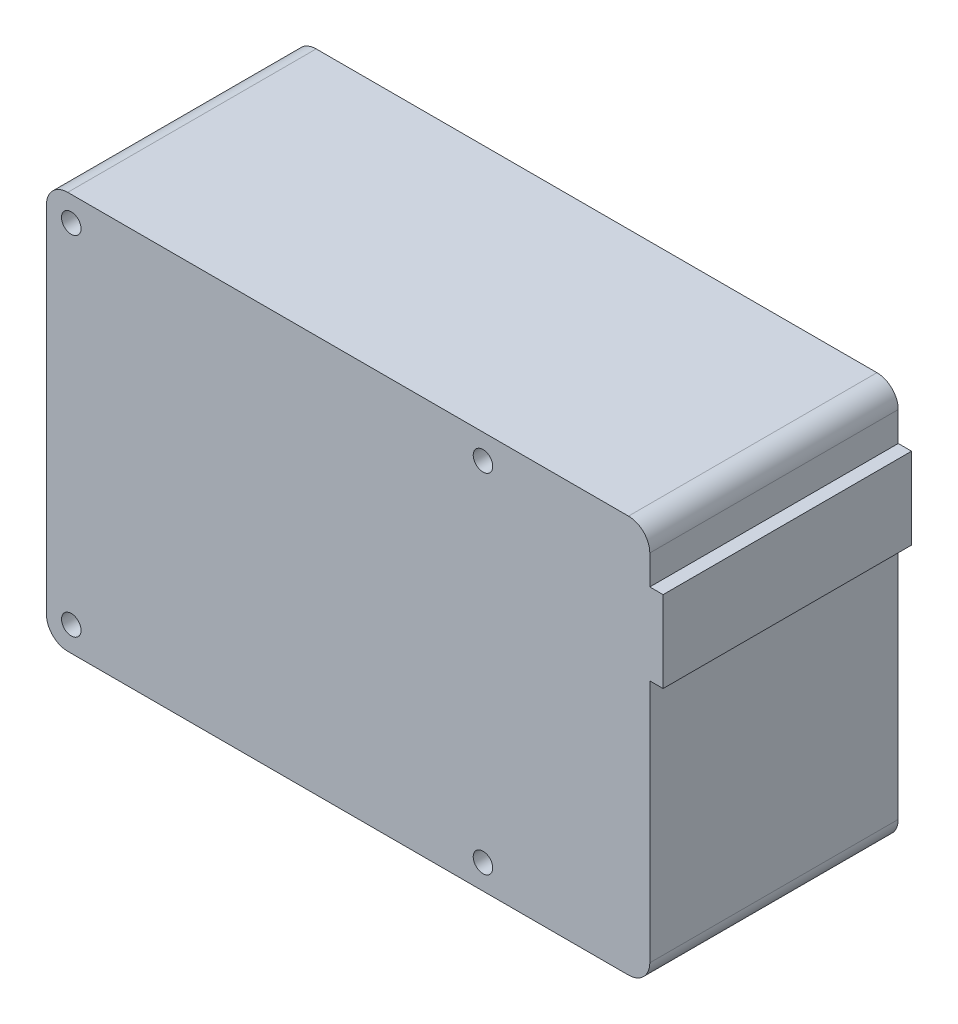
from build123d import *

# Parameters (mm, degrees)
SKETCH1_R           = 1.375
SKETCH1_W           = 53.678190842
SKETCH1_H           = 4.106512076
SKETCH1_W_2         = 1.875741611
SKETCH1_H_2         = 11.459220881
SKETCH1_W_3         = 17.06705209
BOSS_EXTRUDE1_DEPTH = 35


with BuildPart() as part:
    # Sketch1 → Boss-Extrude1 (new body)
    with BuildSketch(Plane.XY):
        with BuildLine():
            Line((39.5, 28), (-39.5, 28))
            ThreePointArc((-39.5, 28), (-41.621320344, 27.121320344), (-42.5, 25))
            Line((-42.5, 25), (-42.5, -25))
            ThreePointArc((-42.5, -25), (-41.621320344, -27.121320344), (-39.5, -28))
            Line((-39.5, -28), (39.5, -28))
            ThreePointArc((39.5, -28), (41.621320344, -27.121320344), (42.5, -25))
            Line((42.5, -25), (42.5, 9.398790598))
            Line((42.5, 9.398790598), (25.43294791, 9.398790598))
            Line((25.43294791, 9.398790598), (25.43294791, 20.858011479))
            Line((25.43294791, 20.858011479), (42.5, 20.858011479))
            Line((42.5, 20.858011479), (42.5, 25))
            ThreePointArc((42.5, 25), (41.621320344, 27.121320344), (39.5, 28))
        make_face()
        with Locations((-39, -24.5)):
            Circle(SKETCH1_R, mode=Mode.SUBTRACT)
        with Locations((19, -24.5)):
            Circle(SKETCH1_R, mode=Mode.SUBTRACT)
        with Locations((-39, 24.5)):
            Circle(SKETCH1_R, mode=Mode.SUBTRACT)
        with Locations((-10.129653796, 24.707102416)):
            Rectangle(SKETCH1_W, SKETCH1_H, mode=Mode.SUBTRACT)
        with Locations((19, 24.5)):
            Circle(SKETCH1_R, mode=Mode.SUBTRACT)
        with Locations((-10.129653796, 24.707102416)):
            Rectangle(SKETCH1_W, SKETCH1_H)
        with Locations((43.437870805, 15.128401039)):
            Rectangle(SKETCH1_W_2, SKETCH1_H_2)
        with Locations((33.966473955, 15.128401039)):
            Rectangle(SKETCH1_W_3, SKETCH1_H_2)
    extrude(amount=BOSS_EXTRUDE1_DEPTH)


solid = part.part
